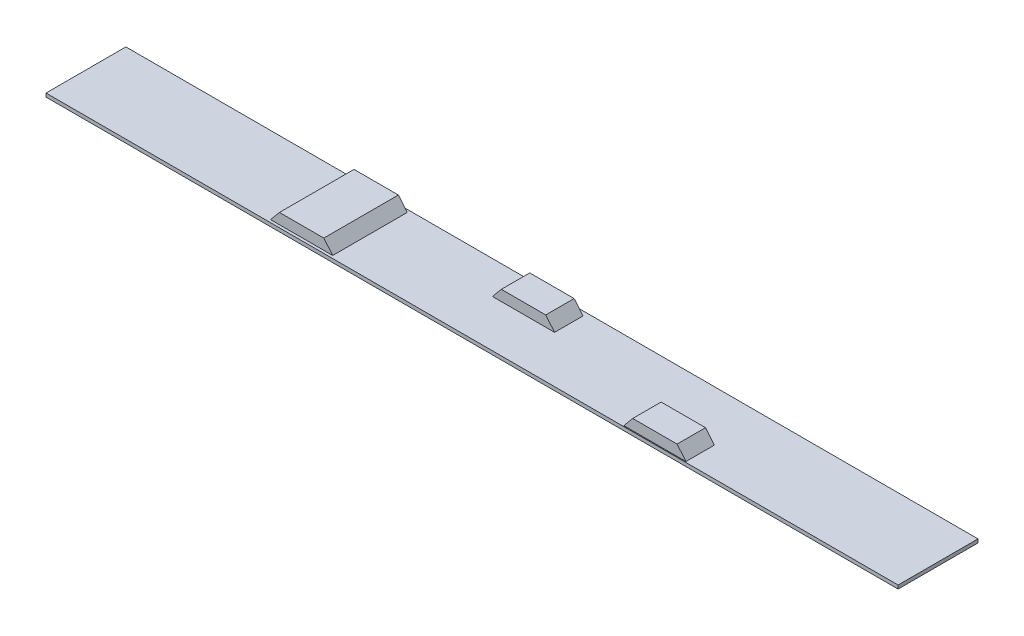
from build123d import *

# Parameters (mm, degrees)
SKETCH1_W           = 2400
SKETCH1_H           = 225
BOSS_EXTRUDE1_DEPTH = 10
BOSS_EXTRUDE2_START = 30
BOSS_EXTRUDE2_DEPTH = 80
BOSS_EXTRUDE3_START = -20
BOSS_EXTRUDE3_DEPTH = 80
BOSS_EXTRUDE4_DEPTH = 105


with BuildPart() as part:
    # Sketch1 → Boss-Extrude1 (new body)
    with BuildSketch(Plane(origin=(0, 0, 0), x_dir=(1, 0, 0), z_dir=(0, 1, 0))):
        Rectangle(SKETCH1_W, SKETCH1_H)
    extrude(amount=BOSS_EXTRUDE1_DEPTH)

    # Sketch2 → Boss-Extrude2 (add)
    with BuildSketch(Plane.XY.offset(BOSS_EXTRUDE2_START)):
        Polygon((425, 10), (450, 40), (575, 40), (600, 10), align=None)
    extrude(amount=BOSS_EXTRUDE2_DEPTH)

    # Sketch3 → Boss-Extrude3 (add)
    with BuildSketch(Plane.XY.offset(BOSS_EXTRUDE3_START)):
        Polygon((100, 10), (-75, 10), (-50, 40), (75, 40), align=None)
    extrude(amount=-BOSS_EXTRUDE3_DEPTH)

    # Sketch4 → Boss-Extrude4 (add, symmetric)
    with BuildSketch(Plane.XY):
        Polygon((-400, 10), (-575, 10), (-550, 40), (-425, 40), align=None)
    extrude(amount=BOSS_EXTRUDE4_DEPTH, both=True)


solid = part.part
